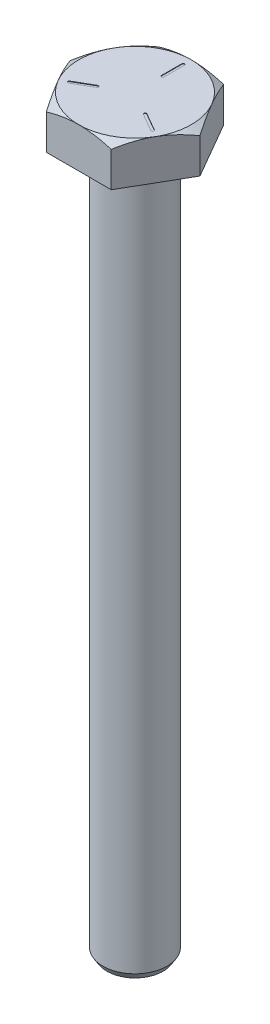
from build123d import *

# Parameters (mm, degrees)
BOSS_EXTRUDE1_DEPTH = 3.9624
CUT_EXTRUDE1_DEPTH  = 0.0508


with BuildPart() as part:
    # Sketch1 → Boss-Extrude1 (new body)
    with BuildSketch(Plane(origin=(0, 0, 0), x_dir=(1, 0, 0), z_dir=(0, 1, 0))):
        Polygon((6.415804866, 0), (3.207902433, 5.55625), (-3.207902433, 5.55625), (-6.415804866, 0), (-3.207902433, -5.55625), (3.207902433, -5.55625), align=None)
    extrude(amount=BOSS_EXTRUDE1_DEPTH)

    # Sketch2 → Cut-Revolve1 (revolve, cut)
    with BuildSketch(Plane.XY):
        Polygon((5.55625, 3.9624), (6.415804866, 3.4544), (6.415804866, 3.9624), align=None)
    revolve(axis=Axis((0, 0, 0), (0, 1, 0)), mode=Mode.SUBTRACT)

    # Sketch3 → Cut-Extrude1 (cut)
    with BuildSketch(Plane(origin=(0, 3.9624, 0), x_dir=(-1, 0, 0), z_dir=(0, -1, 0))):
        with BuildLine():
            Line((0.127, 4.7625), (0.127, 2.7305))
            ThreePointArc((0.127, 2.7305), (0, 2.6035), (-0.127, 2.7305))
            Line((-0.127, 2.7305), (-0.127, 4.7625))
            ThreePointArc((-0.127, 4.7625), (0, 4.8895), (0.127, 4.7625))
        make_face()
        with BuildLine():
            Line((4.060945986, -2.491235226), (2.301182365, -1.475235226))
            ThreePointArc((2.301182365, -1.475235226), (2.254697139, -1.30175), (2.428182365, -1.255264774))
            Line((2.428182365, -1.255264774), (4.187945986, -2.271264774))
            ThreePointArc((4.187945986, -2.271264774), (4.234431212, -2.44475), (4.060945986, -2.491235226))
        make_face()
        with BuildLine():
            Line((-4.187945986, -2.271264774), (-2.428182365, -1.255264774))
            ThreePointArc((-2.428182365, -1.255264774), (-2.254697139, -1.30175), (-2.301182365, -1.475235226))
            Line((-2.301182365, -1.475235226), (-4.060945986, -2.491235226))
            ThreePointArc((-4.060945986, -2.491235226), (-4.234431212, -2.44475), (-4.187945986, -2.271264774))
        make_face()
    extrude(amount=CUT_EXTRUDE1_DEPTH, mode=Mode.SUBTRACT)

    # Bolt Length Sketch → Bolt Length (revolve)
    with BuildSketch(Plane.XY):
        Polygon((0, 0), (0, -69.85), (2.778125, -69.85), (3.175, -69.215), (3.175, 0), align=None)
    revolve(axis=Axis((0, 0, 0), (0, -1, 0)))


solid = part.part
